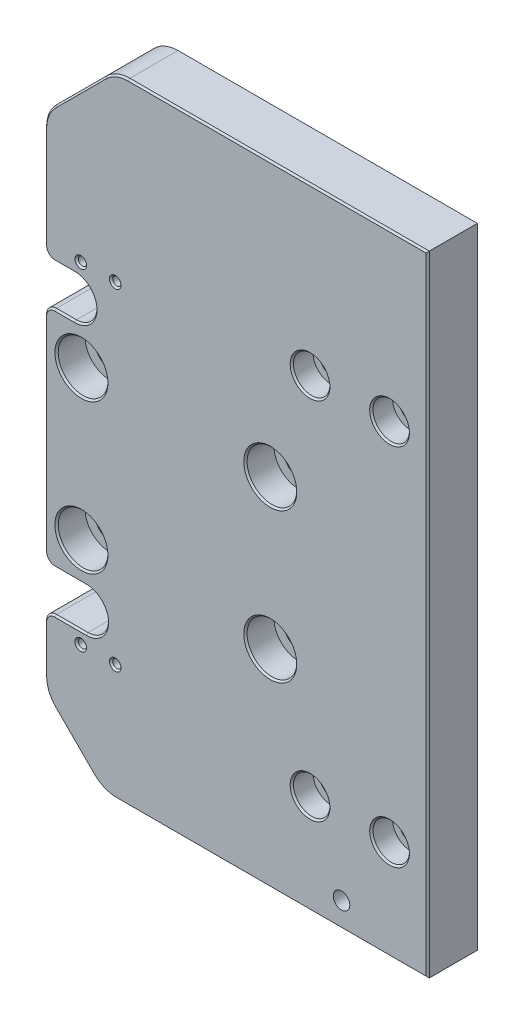
from build123d import *

# Parameters (mm, degrees)
BOSS_EXTRU_1_DEPTH                                  = 15
CBORE_FOR_M6_HEX_SOCKET_HEAD_CAP_SCREW1_D           = 6.6
CBORE_FOR_M6_HEX_SOCKET_HEAD_CAP_SCREW1_CBORE_D     = 11
CBORE_FOR_M6_HEX_SOCKET_HEAD_CAP_SCREW1_CBORE_DEPTH = 6.4
CBORE_FOR_M8_HEX_SOCKET_HEAD_CAP_SCREW1_D           = 9
CBORE_FOR_M8_HEX_SOCKET_HEAD_CAP_SCREW1_CBORE_D     = 15
CBORE_FOR_M8_HEX_SOCKET_HEAD_CAP_SCREW1_CBORE_DEPTH = 8.6
TAP_DRILL_FOR_M6_TAP1_D                             = 5
TAP_DRILL_FOR_M3_TAP1_D                             = 2.5
CUT_EXTRUDE1_DEPTH                                  = 16
FILLET3_R                                           = 10
FILLET4_R                                           = 3
CHAMFER1_SIZE                                       = 0.5


with BuildPart() as part:
    # Esquisse1 → Boss.-Extru.1 (new body)
    with BuildSketch(Plane.XY):
        Polygon((3, 169), (3, 17.5), (20.5, 0), (68.5, 0), (118.5, 0), (118.5, 190), (68.5, 190), (24, 190), align=None)
    extrude(amount=BOSS_EXTRU_1_DEPTH)

    # CBORE for M6 Hex Socket Head Cap Screw1 (through all)
    with Locations(Plane.XY.offset(15)):
        with Locations((83, 30), (107, 140), (107, 30), (83, 140)):
            CounterBoreHole(CBORE_FOR_M6_HEX_SOCKET_HEAD_CAP_SCREW1_D / 2, CBORE_FOR_M6_HEX_SOCKET_HEAD_CAP_SCREW1_CBORE_D / 2, CBORE_FOR_M6_HEX_SOCKET_HEAD_CAP_SCREW1_CBORE_DEPTH)

    # CBORE for M8 Hex Socket Head Cap Screw1 (through all)
    with Locations(Plane.XY.offset(15)):
        with Locations((71, 107.5), (71, 62.5), (14, 62.5), (14, 107.5)):
            CounterBoreHole(CBORE_FOR_M8_HEX_SOCKET_HEAD_CAP_SCREW1_D / 2, CBORE_FOR_M8_HEX_SOCKET_HEAD_CAP_SCREW1_CBORE_D / 2, CBORE_FOR_M8_HEX_SOCKET_HEAD_CAP_SCREW1_CBORE_DEPTH)

    # Tap Drill for M6 Tap1 (through all)
    with Locations(Plane.XY.offset(15)):
        with Locations((92.5, 7.5)):
            Hole(TAP_DRILL_FOR_M6_TAP1_D / 2)

    # Tap Drill for M3 Tap1 (through all)
    with Locations(Plane(origin=(0, 0, 0), x_dir=(-1, 0, 0), z_dir=(0, 0, -1))):
        with Locations((-24.2, 35), (-13.8, 35), (-24.2, 135), (-13.8, 135)):
            Hole(TAP_DRILL_FOR_M3_TAP1_D / 2)

    # Sketch17 → Cut-Extrude1 (cut, through all)
    with BuildSketch(Plane.XY.offset(15)):
        with BuildLine():
            Line((12, 118.8), (-6, 118.8))
            ThreePointArc((-6, 118.8), (-12.2, 125), (-6, 131.2))
            Line((-6, 131.2), (12, 131.2))
            ThreePointArc((12, 131.2), (18.2, 125), (12, 118.8))
        make_face()
        with BuildLine():
            Line((15.5, 38.8), (-2.5, 38.8))
            ThreePointArc((-2.5, 38.8), (-8.7, 45), (-2.5, 51.2))
            Line((-2.5, 51.2), (15.5, 51.2))
            ThreePointArc((15.5, 51.2), (21.7, 45), (15.5, 38.8))
        make_face()
    extrude(amount=-CUT_EXTRUDE1_DEPTH, mode=Mode.SUBTRACT)

    # Fillet3
    fillet3_edges = [part.edges().sort_by_distance(p)[0] for p in [
        (20.5, 0, 7.5),
        (3, 17.5, 7.5),
        (3, 169, 7.5),
        (24, 190, 7.5),
    ]]
    fillet(fillet3_edges, radius=FILLET3_R)

    # Fillet4
    fillet4_edges = [part.edges().sort_by_distance(p)[0] for p in [
        (3, 118.8, 7.5),
        (3, 131.2, 7.5),
        (3, 38.8, 7.5),
        (3, 51.2, 7.5),
    ]]
    fillet(fillet4_edges, radius=FILLET4_R)

    # Chamfer1
    chamfer1_edges = [part.edges().sort_by_distance(p)[0] for p in [
        (22.95, 35, 15),
        (10.75, 38.8, 15),
        (9, 118.8, 15),
        (9, 131.2, 15),
        (18.2, 125, 15),
        (10.75, 51.2, 15),
        (21.7, 45, 15),
        (3, 149.528932188, 15),
        (13.5, 179.5, 15),
        (11.75, 8.75, 15),
        (71.571067812, 0, 15),
        (20.8153013, 0.761204675, 15),
        (24.3153013, 189.238795325, 15),
        (3.761204675, 17.8153013, 15),
        (3.761204675, 168.6846987, 15),
        (3, 85, 15),
        (3, 28.721067812, 15),
        (3.878679656, 37.921320344, 15),
        (3.878679656, 52.078679656, 15),
        (3.878679656, 132.078679656, 15),
        (3.878679656, 117.921320344, 15),
        (118.5, 95, 15),
        (77.5, 140, 15),
        (101.5, 30, 15),
        (101.5, 140, 15),
        (73.321067812, 190, 15),
        (77.5, 30, 15),
        (6.5, 107.5, 15),
        (6.5, 62.5, 15),
        (63.5, 62.5, 15),
        (63.5, 107.5, 15),
        (12.55, 135, 15),
        (22.95, 135, 15),
        (12.55, 35, 15),
    ]]
    chamfer(chamfer1_edges, length=CHAMFER1_SIZE)


solid = part.part
